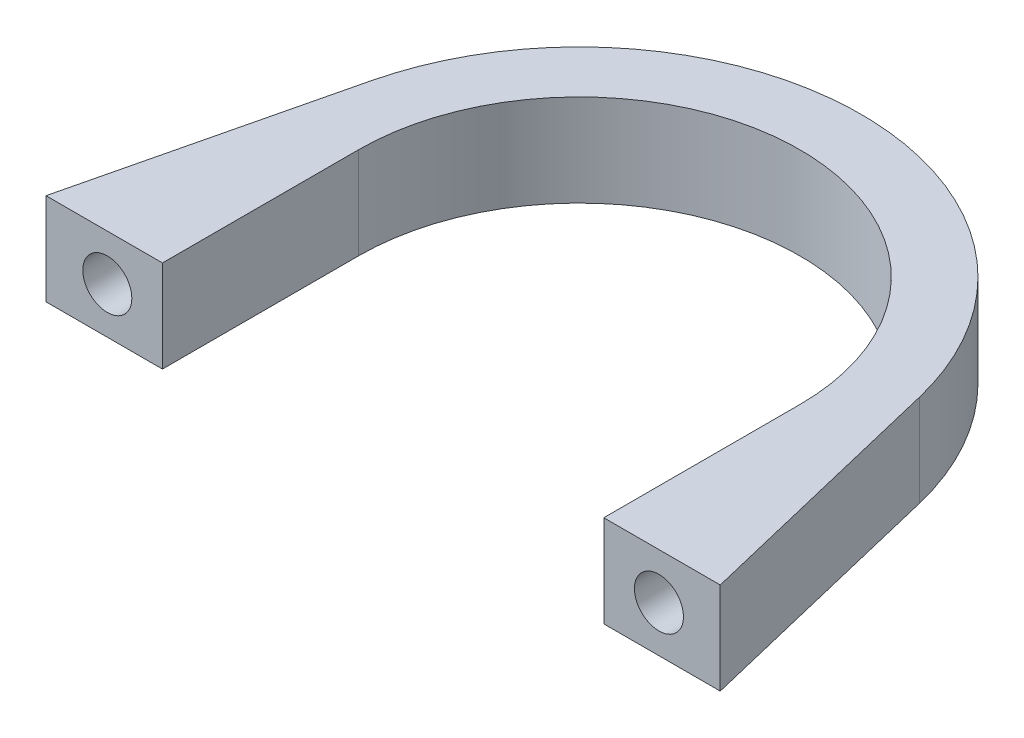
from build123d import *

# Parameters (mm, degrees)
BOSS_EXTRUDE1_DEPTH = 7.5
SKETCH2_R           = 2
CUT_EXTRUDE1_DEPTH  = 4


with BuildPart() as part:
    # Sketch1 → Boss-Extrude1 (new body)
    with BuildSketch(Plane(origin=(0, 0, 0), x_dir=(1, 0, 0), z_dir=(0, 1, 0))):
        with BuildLine():
            Line((-22.363274725, 5.374378434), (-27.5, -16))
            Line((-27.5, -16), (-18, -16))
            Line((-18, -16), (-18, 0))
            ThreePointArc((-18, 0), (0, 18), (18, 0))
            Line((18, 0), (18, -16))
            Line((18, -16), (27.5, -16))
            Line((27.5, -16), (22.363274725, 5.374378434))
            ThreePointArc((22.363274725, 5.374378434), (0, 23), (-22.363274725, 5.374378434))
        make_face()
    extrude(amount=BOSS_EXTRUDE1_DEPTH)

    # Sketch2 → Cut-Extrude1 (cut)
    with BuildSketch(Plane.XY.offset(16)):
        with Locations((-22.5, 3.75)):
            Circle(SKETCH2_R)
        with Locations((22.5, 3.75)):
            Circle(SKETCH2_R)
    extrude(amount=-CUT_EXTRUDE1_DEPTH, mode=Mode.SUBTRACT)


solid = part.part
